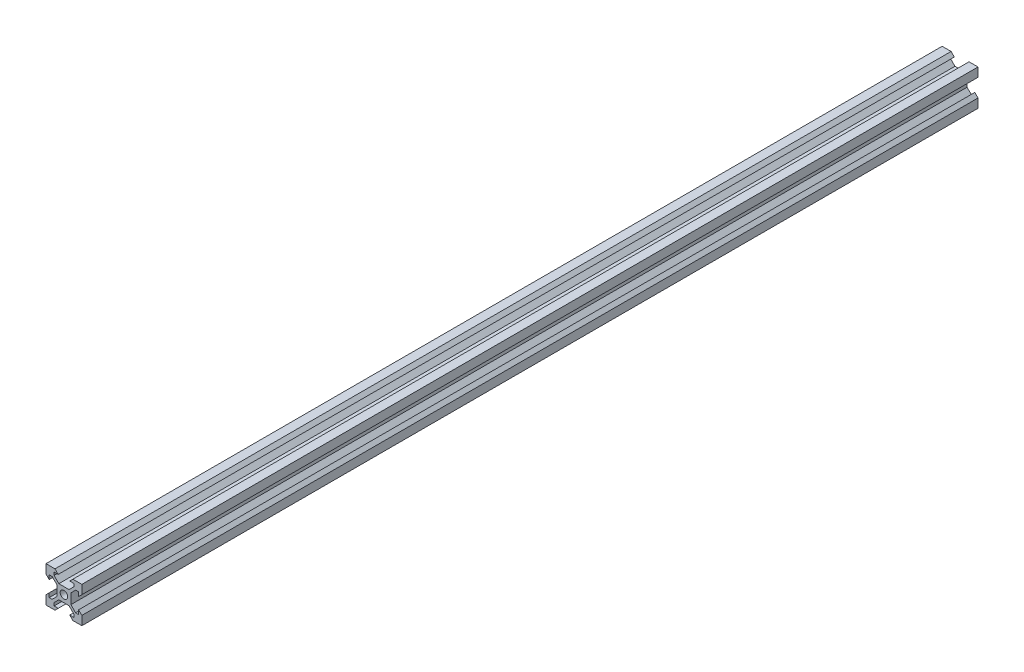
from build123d import *

# Parameters (mm, degrees)
SKETCH1_R           = 2.1
BOSS_EXTRUDE1_DEPTH = 250


with BuildPart() as part:
    # Sketch1 → Boss-Extrude1 (new body, symmetric)
    with BuildSketch(Plane.XY):
        Polygon((-10, 10), (-5, 10), (-3.2, 8.2), (-5.499339828, 8.2), (-5.499339828, 6.56), (-2.84, 3.900660172), (2.84, 3.900660172), (5.499339828, 6.56), (5.499339828, 8.2), (3.2, 8.2), (5, 10), (10, 10), (10, 5), (8.2, 3.2), (8.2, 5.499339828), (6.56, 5.499339828), (3.900660172, 2.84), (3.900660172, -2.84), (6.56, -5.499339828), (8.2, -5.499339828), (8.2, -3.2), (10, -5), (10, -10), (5, -10), (3.2, -8.2), (5.499339828, -8.2), (5.499339828, -6.56), (2.84, -3.900660172), (-2.84, -3.900660172), (-5.499339828, -6.56), (-5.499339828, -8.2), (-3.2, -8.2), (-5, -10), (-10, -10), (-10, -5), (-8.2, -3.2), (-8.2, -5.499339828), (-6.56, -5.499339828), (-3.900660172, -2.84), (-3.900660172, 2.84), (-6.56, 5.499339828), (-8.2, 5.499339828), (-8.2, 3.2), (-10, 5), align=None)
        Circle(SKETCH1_R, mode=Mode.SUBTRACT)
    extrude(amount=BOSS_EXTRUDE1_DEPTH, both=True)


solid = part.part
